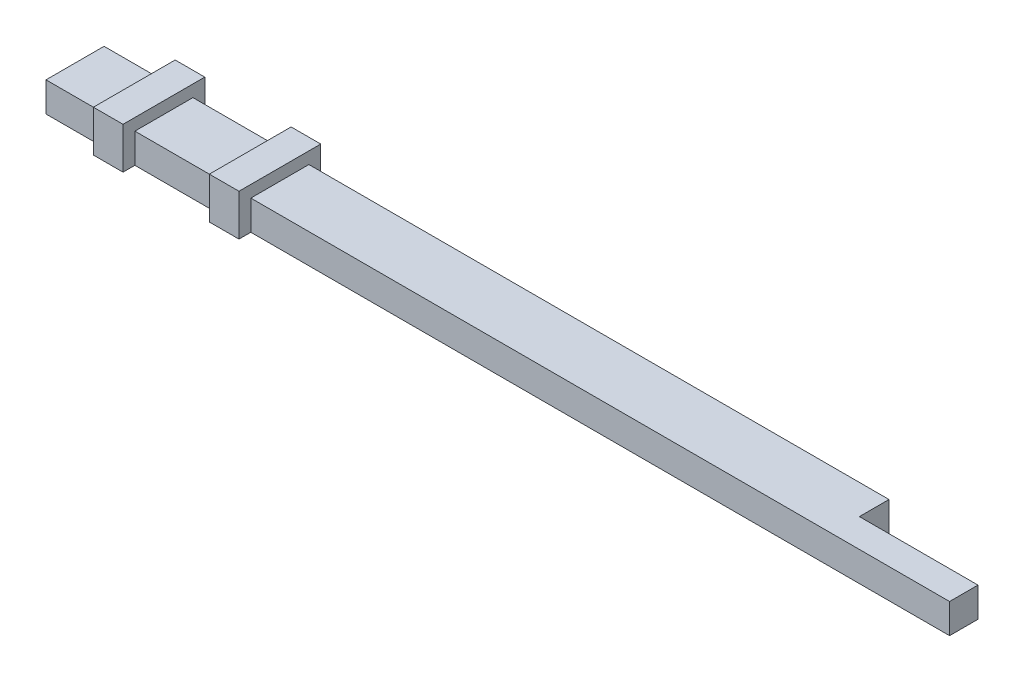
from build123d import *

# Parameters (mm, degrees)
BOSS_EXTRUDE1_DEPTH = 5
SKETCH2_W           = 13.8
SKETCH2_H           = 7
BOSS_EXTRUDE2_DEPTH = 5
SKETCH3_W           = 13.8
SKETCH3_H           = 7
BOSS_EXTRUDE3_DEPTH = 5


with BuildPart() as part:
    # Sketch1 → Boss-Extrude1 (new body)
    with BuildSketch(Plane(origin=(0, 0, 0), x_dir=(1, 0, 0), z_dir=(0, 1, 0))):
        Polygon((132.481495242, 9.8), (132.481495242, 4.8), (142.481495242, 4.8), (152.5, 4.8), (152.5, 0), (142.5, 0), (0, 0), (0, 9.8), align=None)
    extrude(amount=BOSS_EXTRUDE1_DEPTH)

    # Sketch2 → Boss-Extrude2 (add)
    with BuildSketch(Plane.ZY.offset(-10)):
        with Locations((-4.9, 3.5)):
            Rectangle(SKETCH2_W, SKETCH2_H)
    extrude(amount=-BOSS_EXTRUDE2_DEPTH)

    # Sketch3 → Boss-Extrude3 (add)
    with BuildSketch(Plane(origin=(34.57, 0, 0), x_dir=(0, 0, -1), z_dir=(1, 0, 0))):
        with Locations((4.9, 3.5)):
            Rectangle(SKETCH3_W, SKETCH3_H)
    extrude(amount=-BOSS_EXTRUDE3_DEPTH)


solid = part.part
